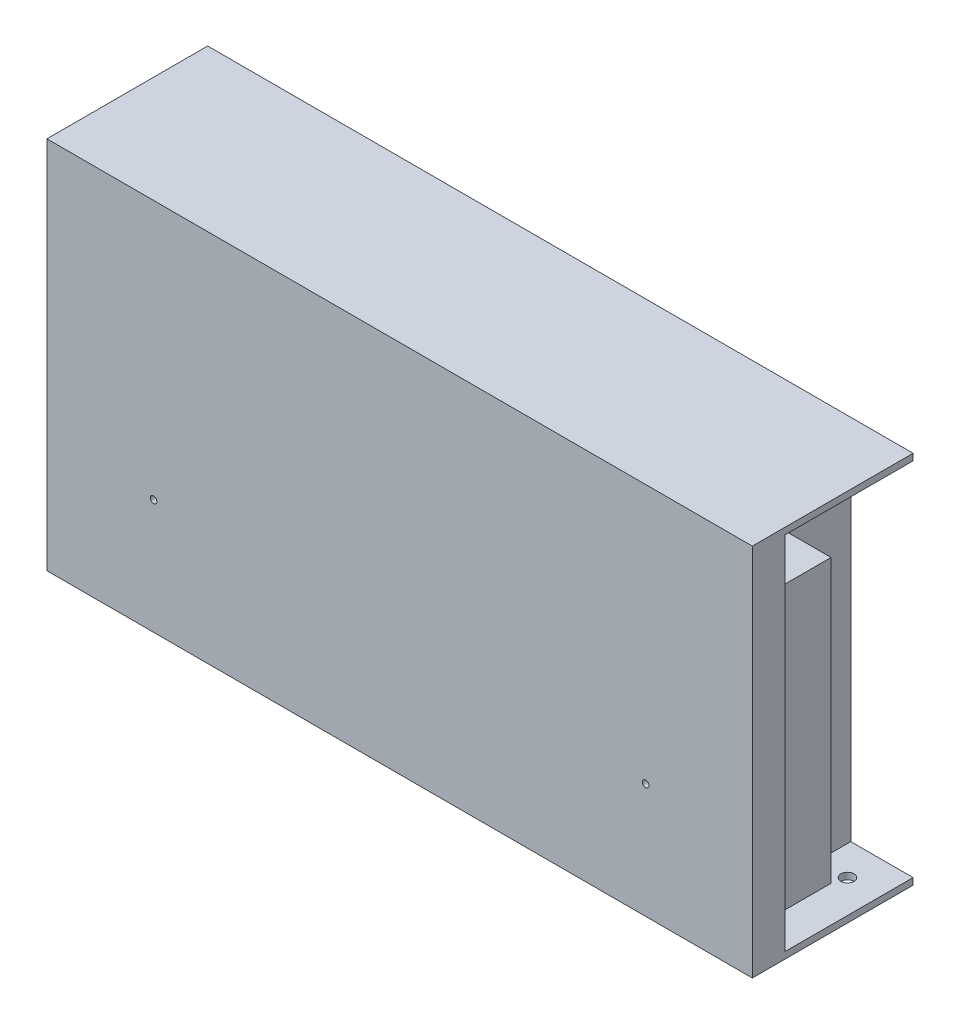
from build123d import *

# Parameters (mm, degrees)
SKETCH1_W           = 215
SKETCH1_H           = 114
BOSS_EXTRUDE1_DEPTH = 49
SKETCH2_W           = 19
SKETCH2_H           = 110
CUT_EXTRUDE1_DEPTH  = 39
SKETCH3_W           = 15
SKETCH3_H           = 86
BOSS_EXTRUDE3_DEPTH = 18
SKETCH4_R           = 2
CUT_EXTRUDE2_DEPTH  = 8
SKETCH5_R           = 1
CUT_EXTRUDE3_DEPTH  = 2


with BuildPart() as part:
    # Sketch1 → Boss-Extrude1 (new body)
    with BuildSketch(Plane.XY):
        Rectangle(SKETCH1_W, SKETCH1_H)
    extrude(amount=BOSS_EXTRUDE1_DEPTH)

    # Sketch2 → Cut-Extrude1 (cut)
    with BuildSketch(Plane(origin=(0, 0, 0), x_dir=(-1, 0, 0), z_dir=(0, 0, -1))):
        with Locations((-98, 0)):
            Rectangle(SKETCH2_W, SKETCH2_H)
    extrude(amount=-CUT_EXTRUDE1_DEPTH, mode=Mode.SUBTRACT)

    # Sketch3 → Boss-Extrude3 (add)
    with BuildSketch(Plane(origin=(0, 0, 39), x_dir=(-1, 0, 0), z_dir=(0, 0, -1))):
        with Locations((-96, -5)):
            Rectangle(SKETCH3_W, SKETCH3_H)
    extrude(amount=BOSS_EXTRUDE3_DEPTH)

    # Sketch4 → Cut-Extrude2 (cut)
    with BuildSketch(Plane(origin=(0, -55, 0), x_dir=(1, 0, 0), z_dir=(0, 1, 0))):
        with Locations((97.5, -10)):
            Circle(SKETCH4_R)
    extrude(amount=-CUT_EXTRUDE2_DEPTH, mode=Mode.SUBTRACT)

    # Sketch5 → Cut-Extrude3 (cut)
    with BuildSketch(Plane.XY.offset(49)):
        with Locations((75, -22)):
            Circle(SKETCH5_R)
        with Locations((-75, -22)):
            Circle(SKETCH5_R)
    extrude(amount=-CUT_EXTRUDE3_DEPTH, mode=Mode.SUBTRACT)


solid = part.part
